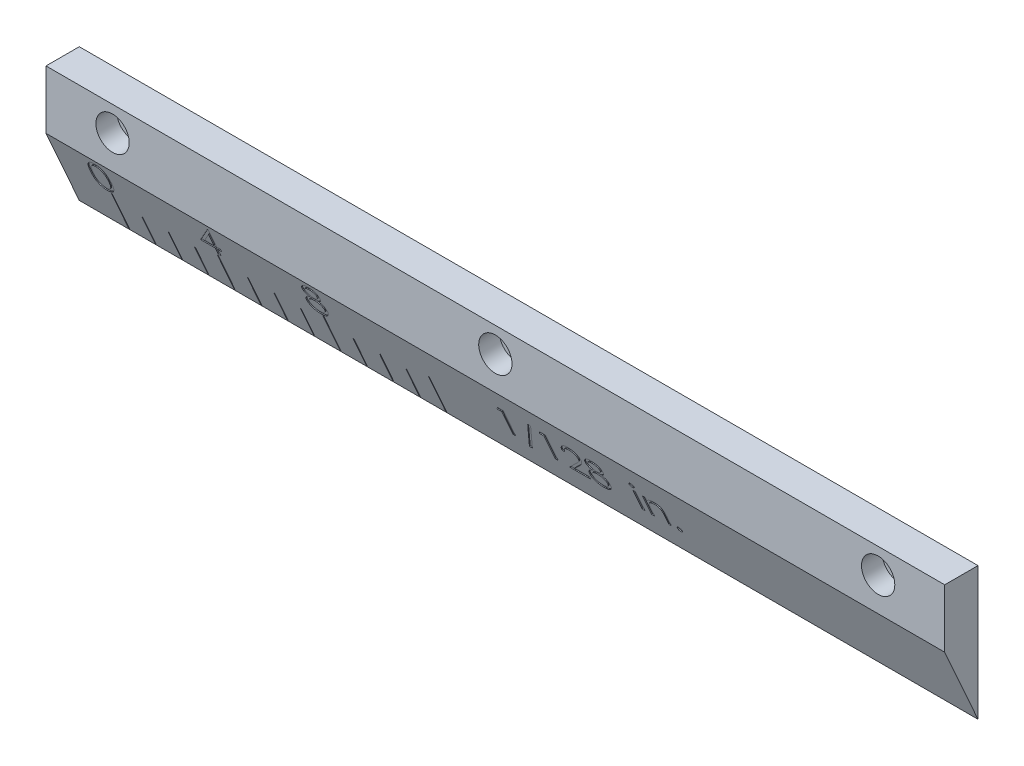
from build123d import *

# Parameters (mm, degrees)
SKETCH1_W           = 54
SKETCH1_H           = 8
BOSS_EXTRUDE1_DEPTH = 1
CUT_EXTRUDE1_DEPTH  = 55
SKETCH3_R           = 1
CUT_EXTRUDE2_DEPTH  = 1.25
SKETCH4_R           = 0.5
CUT_EXTRUDE3_DEPTH  = 1.75
SKETCH5_W           = 0.05
SKETCH5_H           = 2.58
SKETCH5_H_2         = 2
CUT_EXTRUDE4_DEPTH  = 0.05
CUT_EXTRUDE5_DEPTH  = 0.05
SKETCH7_W           = 0.166212607
SKETCH7_H           = 1.353445513
CUT_EXTRUDE6_DEPTH  = 0.05


with BuildPart() as part:
    # Sketch1 → Boss-Extrude1 (new body, symmetric)
    with BuildSketch(Plane.XY):
        Rectangle(SKETCH1_W, SKETCH1_H)
    extrude(amount=BOSS_EXTRUDE1_DEPTH, both=True)

    # Sketch2 → Cut-Extrude1 (cut, through all)
    with BuildSketch(Plane(origin=(27, 0, 0), x_dir=(0, 0, -1), z_dir=(1, 0, 0))):
        Polygon((-1, 0.492073548), (1, -4), (-1, -4), align=None)
    extrude(amount=-CUT_EXTRUDE1_DEPTH, mode=Mode.SUBTRACT)

    # Sketch3 → Cut-Extrude2 (cut)
    with BuildSketch(Plane.XY.offset(1)):
        with Locations((23, 2.5)):
            Circle(SKETCH3_R)
        with Locations((0, 2.5)):
            Circle(SKETCH3_R)
        with Locations((-23, 2.5)):
            Circle(SKETCH3_R)
    extrude(amount=-CUT_EXTRUDE2_DEPTH, mode=Mode.SUBTRACT)

    # Sketch4 → Cut-Extrude3 (cut, through all)
    with BuildSketch(Plane.XY.offset(-0.25)):
        with Locations((-23, 2.5)):
            Circle(SKETCH4_R)
        with Locations((0, 2.5)):
            Circle(SKETCH4_R)
        with Locations((23, 2.5)):
            Circle(SKETCH4_R)
    extrude(amount=-CUT_EXTRUDE3_DEPTH, mode=Mode.SUBTRACT)

    # Sketch5 → Cut-Extrude4 (cut)
    with BuildSketch(Plane(origin=(0, -0.290166375, 0.651724348), x_dir=(1, 0, 0), z_dir=(0, -0.406736643, 0.913545458))):
        with Locations((-23.975, -2.720918474)):
            Rectangle(SKETCH5_W, SKETCH5_H)
        with Locations((-22.3875, -3.010918474)):
            Rectangle(SKETCH5_W, SKETCH5_H_2)
        with Locations((-20.8, -3.010918474)):
            Rectangle(SKETCH5_W, SKETCH5_H_2)
        with Locations((-19.2125, -3.010918474)):
            Rectangle(SKETCH5_W, SKETCH5_H_2)
        with Locations((-17.625, -2.720918474)):
            Rectangle(SKETCH5_W, SKETCH5_H)
        with Locations((-16.0375, -3.010918474)):
            Rectangle(SKETCH5_W, SKETCH5_H_2)
        with Locations((-14.45, -3.010918474)):
            Rectangle(SKETCH5_W, SKETCH5_H_2)
        with Locations((-12.8625, -3.010918474)):
            Rectangle(SKETCH5_W, SKETCH5_H_2)
        with Locations((-11.275, -2.720918474)):
            Rectangle(SKETCH5_W, SKETCH5_H)
        with Locations((-9.6875, -3.010918474)):
            Rectangle(SKETCH5_W, SKETCH5_H_2)
        with Locations((-8.1, -3.010918474)):
            Rectangle(SKETCH5_W, SKETCH5_H_2)
        with Locations((-6.5125, -3.010918474)):
            Rectangle(SKETCH5_W, SKETCH5_H_2)
        with Locations((-4.925, -2.720918474)):
            Rectangle(SKETCH5_W, SKETCH5_H)
    extrude(amount=-CUT_EXTRUDE4_DEPTH, mode=Mode.SUBTRACT)

    # Sketch6 → Cut-Extrude5 (cut)
    with BuildSketch(Plane(origin=(0, -0.290166375, 0.651724348), x_dir=(1, 0, 0), z_dir=(0, -0.406736643, 0.913545458))):
        with BuildLine():
            add(Edge.make_bspline(
                [(-24.826395444, -0.386042742), (-24.826221867, -0.356357875), (-24.825884693, -0.298694591), (-24.822133737, -0.214671052), (-24.815902618, -0.135846232), (-24.807363258, -0.06221636), (-24.796971494, 0.006237574), (-24.783099132, 0.069332633), (-24.767323191, 0.127360842), (-24.749039188, 0.180511426), (-24.72840815, 0.22950046), (-24.705953354, 0.275233796), (-24.68078365, 0.317642235), (-24.654337534, 0.357402649), (-24.625544479, 0.393864188), (-24.595223869, 0.427541763), (-24.562192293, 0.457657035), (-24.527572618, 0.48509237), (-24.491051405, 0.509142716), (-24.453669661, 0.530326707), (-24.415170084, 0.548424136), (-24.375447562, 0.562653659), (-24.334859125, 0.574406898), (-24.293262886, 0.582444383), (-24.250590164, 0.587501581), (-24.221786863, 0.587985063), (-24.207179281, 0.588230261)],
                knots=[0, 0, 0, 0, 8.9049e-05, 0.00017298, 0.000252256, 0.00032621, 0.000395319, 0.000459867, 0.000519903, 0.000575635, 0.000628347, 0.000679285, 0.000728344, 0.000776193, 0.000822433, 0.000867605, 0.000911979, 0.000956364, 0.000999993, 0.001043021, 0.001085181, 0.001127434, 0.001169477, 0.001211825, 0.001254394, 0.001298198, 0.001298198, 0.001298198, 0.001298198], degree=3))
            add(Edge.make_bspline(
                [(-24.207179281, 0.588230261), (-24.192449674, 0.587972125), (-24.163157119, 0.587458775), (-24.119849921, 0.582524856), (-24.077543214, 0.574338053), (-24.036417366, 0.562738204), (-23.99613456, 0.548347158), (-23.957009878, 0.530309392), (-23.918800297, 0.509312658), (-23.88211302, 0.484640856), (-23.846545286, 0.457133569), (-23.812970739, 0.426038323), (-23.781386323, 0.391669097), (-23.75139564, 0.35439361), (-23.723849553, 0.31349692), (-23.697616945, 0.269690328), (-23.674136743, 0.222207745), (-23.651522978, 0.171841415), (-23.632003614, 0.117197728), (-23.614400226, 0.058584709), (-23.600176771, -0.004689965), (-23.588329115, -0.072294311), (-23.579150774, -0.144476604), (-23.572466001, -0.221082113), (-23.568934827, -0.302161236), (-23.568269822, -0.357595598), (-23.567928563, -0.386042742)],
                knots=[0, 0, 0, 0, 4.4175e-05, 8.785e-05, 0.000130562, 0.00017332, 0.000215921, 0.000258755, 0.00030243, 0.000346574, 0.000391251, 0.000437198, 0.00048367, 0.000531182, 0.000580577, 0.000631479, 0.000684243, 0.000739392, 0.000797018, 0.000858177, 0.000922887, 0.000991446, 0.001064018, 0.001141106, 0.001222072, 0.001307417, 0.001307417, 0.001307417, 0.001307417], degree=3))
            add(Edge.make_bspline(
                [(-23.567928563, -0.386042742), (-23.56827336, -0.41436581), (-23.568945183, -0.469552153), (-23.572426415, -0.550266461), (-23.579283691, -0.626465426), (-23.587861476, -0.698331795), (-23.599741777, -0.765566452), (-23.614349511, -0.828402056), (-23.63056864, -0.887109961), (-23.650589552, -0.941209215), (-23.67250272, -0.991454502), (-23.696344428, -1.038374201), (-23.721887211, -1.082383031), (-23.749715422, -1.12312873), (-23.779377019, -1.160899936), (-23.811506849, -1.195029928), (-23.845199201, -1.226341076), (-23.880871604, -1.254202562), (-23.91813105, -1.278589104), (-23.956209395, -1.3003981), (-23.995782268, -1.317983735), (-24.035952873, -1.333083527), (-24.0772958, -1.3446196), (-24.119759515, -1.352596181), (-24.163128023, -1.358190451), (-24.192444684, -1.358617213), (-24.207179281, -1.358831705)],
                knots=[0, 0, 0, 0, 8.4974e-05, 0.000165569, 0.000242288, 0.000314445, 0.000382639, 0.000446988, 0.000507939, 0.000565216, 0.000619877, 0.000672309, 0.000723023, 0.000772418, 0.000820221, 0.000866944, 0.000912891, 0.000958089, 0.001002542, 0.001046399, 0.00108957, 0.001132299, 0.001175057, 0.001218132, 0.00126185, 0.001306025, 0.001306025, 0.001306025, 0.001306025], degree=3))
            add(Edge.make_bspline(
                [(-24.207179281, -1.358831705), (-24.221786458, -1.358584925), (-24.25058896, -1.358098324), (-24.293267535, -1.353063974), (-24.334691995, -1.344970103), (-24.375066752, -1.33363715), (-24.41459895, -1.319765133), (-24.452749901, -1.301692142), (-24.489943801, -1.280877864), (-24.526081416, -1.25717362), (-24.560483684, -1.230015896), (-24.593344196, -1.199978127), (-24.623837436, -1.166310738), (-24.652218811, -1.129545337), (-24.679192599, -1.090020163), (-24.704004893, -1.047195566), (-24.726955303, -1.001241351), (-24.747933317, -0.951860623), (-24.766532818, -0.898332807), (-24.78296223, -0.840045534), (-24.795934305, -0.776484343), (-24.807037786, -0.708159736), (-24.815993605, -0.634778115), (-24.822107769, -0.55629964), (-24.825886715, -0.472773217), (-24.826222773, -0.415480462), (-24.826395444, -0.386042742)],
                knots=[0, 0, 0, 0, 4.3804e-05, 8.6374e-05, 0.000128721, 0.000170307, 0.000212085, 0.000254245, 0.000296767, 0.000339883, 0.000383747, 0.000428121, 0.000473293, 0.000519825, 0.000567366, 0.000616745, 0.000668181, 0.000721379, 0.000777583, 0.000838076, 0.000902909, 0.000972077, 0.001045706, 0.001124613, 0.001208173, 0.00129648, 0.00129648, 0.00129648, 0.00129648], degree=3))
        make_face()
        with BuildLine():
            add(Edge.make_bspline(
                [(-24.660182837, -0.385300722), (-24.660119629, -0.410038575), (-24.659996956, -0.45804989), (-24.656792217, -0.527816949), (-24.652426469, -0.592888748), (-24.646795449, -0.653347911), (-24.638433056, -0.708989793), (-24.629063214, -0.760197084), (-24.617660683, -0.806698788), (-24.604169569, -0.848814005), (-24.588803047, -0.88725747), (-24.572025361, -0.92302978), (-24.554001562, -0.956553513), (-24.533830178, -0.987527547), (-24.51186179, -1.016052892), (-24.488592607, -1.042634433), (-24.463154198, -1.066339502), (-24.427962635, -1.094769963), (-24.381503667, -1.124148838), (-24.322967009, -1.149731977), (-24.262817454, -1.16580936), (-24.221991584, -1.167853931), (-24.201614127, -1.16887444)],
                knots=[0, 0, 0, 0, 7.4206e-05, 0.000144019, 0.000209468, 0.000269864, 0.000326111, 0.000378211, 0.000425993, 0.00046964, 0.00051077, 0.000550106, 0.000588125, 0.000624862, 0.000660852, 0.000696069, 0.000730714, 0.000765016, 0.000831715, 0.000894853, 0.000956132, 0.001017199, 0.001017199, 0.001017199, 0.001017199], degree=3))
            add(Edge.make_bspline(
                [(-24.201614127, -1.16887444), (-24.181104859, -1.168028948), (-24.140128667, -1.166339708), (-24.080262034, -1.150042043), (-24.022143516, -1.125451912), (-23.976597114, -1.096375524), (-23.941945935, -1.068685116), (-23.917119028, -1.045076531), (-23.894332027, -1.018641551), (-23.872719762, -0.990119841), (-23.852897668, -0.958966485), (-23.834872591, -0.925331288), (-23.81842432, -0.889120848), (-23.809053283, -0.863842695), (-23.804262114, -0.850918627)],
                knots=[0, 0, 0, 0, 6.1406e-05, 0.000122686, 0.000184848, 0.00025021, 0.00028399, 0.000317842, 0.000352813, 0.000388579, 0.000425115, 0.00046346, 0.000502978, 0.000544318, 0.000544318, 0.000544318, 0.000544318], degree=3))
            add(Edge.make_bspline(
                [(-23.804262114, -0.850918627), (-23.79867847, -0.83439289), (-23.787341278, -0.800838557), (-23.772730048, -0.748787791), (-23.761223107, -0.694176328), (-23.750870826, -0.637330537), (-23.743804834, -0.577831195), (-23.73811745, -0.5158624), (-23.734767461, -0.45137743), (-23.734352197, -0.40756508), (-23.73414117, -0.385300722)],
                knots=[0, 0, 0, 0, 5.2327e-05, 0.000106246, 0.000162062, 0.000219704, 0.000279527, 0.000341735, 0.000406377, 0.000473169, 0.000473169, 0.000473169, 0.000473169], degree=3))
            add(Edge.make_bspline(
                [(-23.73414117, -0.385300722), (-23.734432312, -0.363039965), (-23.735001848, -0.319493165), (-23.737178833, -0.255718961), (-23.742800474, -0.195146438), (-23.749044175, -0.137514646), (-23.758250204, -0.083142611), (-23.76817621, -0.031575158), (-23.781511852, 0.01654886), (-23.795756899, 0.061982888), (-23.812060734, 0.104210735), (-23.83000781, 0.14342928), (-23.849175157, 0.179827864), (-23.869993759, 0.21330662), (-23.892216475, 0.244015507), (-23.916429845, 0.271338814), (-23.941673409, 0.296123376), (-23.977030836, 0.324413986), (-24.023319315, 0.353259758), (-24.080916803, 0.379805806), (-24.140855852, 0.395050194), (-24.181375972, 0.397199503), (-24.201614127, 0.398272996)],
                knots=[0, 0, 0, 0, 6.6791e-05, 0.000130658, 0.000191355, 0.000249248, 0.000304509, 0.000356751, 0.0004067, 0.00045422, 0.000499556, 0.00054239, 0.00058355, 0.000622877, 0.000660574, 0.000697117, 0.000732275, 0.000766577, 0.000832764, 0.000895373, 0.000956201, 0.001016899, 0.001016899, 0.001016899, 0.001016899], degree=3))
            add(Edge.make_bspline(
                [(-24.201614127, 0.398272996), (-24.222098482, 0.397198022), (-24.263104509, 0.395046116), (-24.323666552, 0.379862603), (-24.381718438, 0.353397408), (-24.427884512, 0.324318445), (-24.463266599, 0.296622755), (-24.488181191, 0.272605756), (-24.511541874, 0.246334613), (-24.533061865, 0.217546933), (-24.553217444, 0.18660901), (-24.57172823, 0.153277455), (-24.588406151, 0.117383358), (-24.603796718, 0.078957161), (-24.617328985, 0.036845578), (-24.628491207, -0.009598848), (-24.638803106, -0.060643266), (-24.646103102, -0.116586505), (-24.652592673, -0.177060811), (-24.65676322, -0.242295059), (-24.660007677, -0.312179127), (-24.660123281, -0.360438682), (-24.660182837, -0.385300722)],
                knots=[0, 0, 0, 0, 6.1437e-05, 0.000122985, 0.000185932, 0.00025212, 0.000286191, 0.000320567, 0.000355783, 0.000391549, 0.000428286, 0.000466484, 0.00050582, 0.00054695, 0.000590597, 0.000638378, 0.000690184, 0.000746746, 0.000807549, 0.000872628, 0.000942812, 0.001017389, 0.001017389, 0.001017389, 0.001017389], degree=3))
        make_face(mode=Mode.SUBTRACT)
        Polygon((-17.40433473, 0.588230261), (-17.370572794, 0.588230261), (-17.370572794, -0.693981277), (-17.156870871, -0.693981277), (-17.156870871, -0.883938542), (-17.370572794, -0.883938542), (-17.370572794, -1.311342389), (-17.536785401, -1.311342389), (-17.536785401, -0.883938542), (-18.415337751, -0.883938542), align=None)
        Polygon((-17.536785401, -0.693981277), (-17.536785401, 0.110369016), (-18.088848702, -0.693981277), align=None, mode=Mode.SUBTRACT)
        with BuildLine():
            add(Edge.make_bspline(
                [(-11.103838102, -0.279562791), (-11.088678246, -0.28746746), (-11.059111463, -0.302884203), (-11.017001857, -0.327707849), (-10.978518211, -0.35387036), (-10.942592788, -0.380136002), (-10.909856765, -0.407510667), (-10.88067618, -0.436103213), (-10.854330231, -0.465199942), (-10.831350225, -0.495293566), (-10.811137732, -0.526304134), (-10.79366881, -0.558313041), (-10.778737207, -0.591250139), (-10.766903486, -0.625474961), (-10.757155287, -0.660484766), (-10.75044778, -0.696731615), (-10.746840494, -0.733976662), (-10.746158497, -0.759148222), (-10.745813179, -0.771893437)],
                knots=[0, 0, 0, 0, 5.1287e-05, 0.000100026, 0.000146537, 0.000190837, 0.000233495, 0.000274424, 0.000313308, 0.000351153, 0.00038789, 0.000424251, 0.000460453, 0.000496241, 0.000532783, 0.000569386, 0.000606672, 0.000644915, 0.000644915, 0.000644915, 0.000644915], degree=3))
            add(Edge.make_bspline(
                [(-10.745813179, -0.771893437), (-10.746221389, -0.789725154), (-10.74702939, -0.825020812), (-10.754067298, -0.877115213), (-10.764604582, -0.927709781), (-10.779992491, -0.976793424), (-10.79994916, -1.024095301), (-10.824543153, -1.069655901), (-10.852383249, -1.114221953), (-10.874741725, -1.141643053), (-10.886055066, -1.15551807)],
                knots=[0, 0, 0, 0, 5.3472e-05, 0.000105841, 0.000157433, 0.00020836, 0.000259902, 0.000311189, 0.000363575, 0.000417233, 0.000417233, 0.000417233, 0.000417233], degree=3))
            add(Edge.make_bspline(
                [(-10.886055066, -1.15551807), (-10.9007852, -1.171707275), (-10.930063444, -1.203885632), (-10.98021941, -1.245663769), (-11.035264324, -1.280773656), (-11.094985191, -1.309386701), (-11.159222374, -1.331657134), (-11.227962185, -1.347660467), (-11.301338633, -1.356826919), (-11.351771111, -1.358151947), (-11.377643691, -1.358831705)],
                knots=[0, 0, 0, 0, 6.5605e-05, 0.000130399, 0.000195135, 0.000261013, 0.000328598, 0.000398703, 0.000472378, 0.000549991, 0.000549991, 0.000549991, 0.000549991], degree=3))
            add(Edge.make_bspline(
                [(-11.377643691, -1.358831705), (-11.402521609, -1.358221852), (-11.450931511, -1.35703514), (-11.521394221, -1.348994753), (-11.587076012, -1.334904174), (-11.648358787, -1.315618901), (-11.704873096, -1.290530989), (-11.756457903, -1.259305706), (-11.803857464, -1.223199901), (-11.845633306, -1.181176618), (-11.882721774, -1.136166827), (-11.915301535, -1.089731601), (-11.942381152, -1.041866699), (-11.965308407, -0.99328583), (-11.982859819, -0.943308073), (-11.995015947, -0.892190566), (-12.002736125, -0.840022595), (-12.003763309, -0.804816261), (-12.004280059, -0.787104859)],
                knots=[0, 0, 0, 0, 7.4632e-05, 0.000145227, 0.000212392, 0.000275869, 0.000337649, 0.000397395, 0.000456391, 0.000515943, 0.000574705, 0.000631208, 0.000685878, 0.000739491, 0.000792176, 0.000844458, 0.000896927, 0.000950045, 0.000950045, 0.000950045, 0.000950045], degree=3))
            add(Edge.make_bspline(
                [(-12.004280059, -0.787104859), (-12.003974264, -0.774108953), (-12.003369904, -0.748424456), (-11.999186922, -0.71047827), (-11.992462028, -0.673544482), (-11.983328899, -0.637486671), (-11.970951147, -0.602567348), (-11.956006352, -0.568621056), (-11.93857986, -0.53560947), (-11.918428577, -0.503352062), (-11.894985423, -0.47230082), (-11.868440491, -0.441928773), (-11.838263244, -0.412707202), (-11.8047894, -0.384279085), (-11.768401497, -0.356140132), (-11.728154388, -0.329811059), (-11.685115004, -0.303427886), (-11.65452631, -0.287654314), (-11.63883493, -0.279562791)],
                knots=[0, 0, 0, 0, 3.8984e-05, 7.7047e-05, 0.000114379, 0.000151543, 0.000188505, 0.000225384, 0.000262726, 0.000300401, 0.000339357, 0.00037932, 0.000421298, 0.000465242, 0.000511027, 0.000559184, 0.00060945, 0.000662395, 0.000662395, 0.000662395, 0.000662395], degree=3))
            add(Edge.make_bspline(
                [(-11.63883493, -0.279562791), (-11.660314533, -0.267849809), (-11.701905055, -0.245170198), (-11.756975134, -0.203500014), (-11.804277673, -0.158368545), (-11.842512461, -0.108822778), (-11.872607348, -0.056410474), (-11.893254693, -0.001459557), (-11.907222832, 0.055011053), (-11.908606512, 0.093590582), (-11.909301427, 0.112966088)],
                knots=[0, 0, 0, 0, 7.3308e-05, 0.000141945, 0.00020649, 0.000268902, 0.000329048, 0.000387063, 0.000444571, 0.000502592, 0.000502592, 0.000502592, 0.000502592], degree=3))
            add(Edge.make_bspline(
                [(-11.909301427, 0.112966088), (-11.908436015, 0.132702713), (-11.906696386, 0.17237677), (-11.892629379, 0.231435011), (-11.869705843, 0.289440443), (-11.838526816, 0.346111924), (-11.799692747, 0.399531413), (-11.75310145, 0.447442664), (-11.699865539, 0.489411657), (-11.640250751, 0.524641548), (-11.576096576, 0.553313734), (-11.508407839, 0.57309315), (-11.438363903, 0.586023928), (-11.390687193, 0.587487949), (-11.366513382, 0.588230261)],
                knots=[0, 0, 0, 0, 5.9158e-05, 0.000118919, 0.000181064, 0.000245821, 0.000312459, 0.000378578, 0.000445677, 0.000515222, 0.000585816, 0.000655894, 0.000726345, 0.000798807, 0.000798807, 0.000798807, 0.000798807], degree=3))
            add(Edge.make_bspline(
                [(-11.366513382, 0.588230261), (-11.342963447, 0.587464904), (-11.296525657, 0.585955708), (-11.228266, 0.573368486), (-11.162953669, 0.552344948), (-11.100813893, 0.523824334), (-11.042959113, 0.488694578), (-10.991840391, 0.446149115), (-10.946685233, 0.398449211), (-10.909334324, 0.345045921), (-10.878556462, 0.288592202), (-10.857124735, 0.229525285), (-10.843391815, 0.169121408), (-10.84165966, 0.128249631), (-10.840791811, 0.107771944)],
                knots=[0, 0, 0, 0, 7.061e-05, 0.000139235, 0.000207405, 0.00027597, 0.000343928, 0.000409816, 0.000474911, 0.000540381, 0.000604785, 0.000667229, 0.000728357, 0.000789735, 0.000789735, 0.000789735, 0.000789735], degree=3))
            add(Edge.make_bspline(
                [(-10.840791811, 0.107771944), (-10.841550933, 0.08767596), (-10.843041805, 0.048208588), (-10.855583023, -0.009325862), (-10.876703818, -0.063206691), (-10.905540312, -0.114045295), (-10.943124633, -0.160919671), (-10.988955087, -0.204425886), (-11.042666286, -0.244921333), (-11.083021005, -0.267774117), (-11.103838102, -0.279562791)],
                knots=[0, 0, 0, 0, 6.0242e-05, 0.000118312, 0.000175635, 0.000233296, 0.000292977, 0.000355166, 0.000422467, 0.000494176, 0.000494176, 0.000494176, 0.000494176], degree=3))
        make_face()
        with BuildLine():
            add(Edge.make_bspline(
                [(-11.375788639, 0.398272996), (-11.388780108, 0.397928275), (-11.4141971, 0.397253851), (-11.451465605, 0.393730322), (-11.486905149, 0.386875912), (-11.52088601, 0.37775376), (-11.552942299, 0.365430533), (-11.583509375, 0.350934008), (-11.612067013, 0.333309548), (-11.638959953, 0.313539247), (-11.663169738, 0.291794251), (-11.684656313, 0.269138658), (-11.702504107, 0.245127513), (-11.717660027, 0.22035809), (-11.728656913, 0.194095243), (-11.736893024, 0.167144162), (-11.742460594, 0.139164271), (-11.742877784, 0.120042035), (-11.74308882, 0.110369016)],
                knots=[0, 0, 0, 0, 3.8984e-05, 7.627e-05, 0.000112143, 0.000147156, 0.000181678, 0.000215032, 0.000248501, 0.00028219, 0.000315034, 0.000346008, 0.000375689, 0.00040464, 0.000432895, 0.000460827, 0.000489134, 0.00051811, 0.00051811, 0.00051811, 0.00051811], degree=3))
            add(Edge.make_bspline(
                [(-11.74308882, 0.110369016), (-11.742725088, 0.10069558), (-11.742006302, 0.08157948), (-11.736447338, 0.053350626), (-11.728162253, 0.025610843), (-11.715117944, -0.000980264), (-11.699472413, -0.027345125), (-11.68016234, -0.05282481), (-11.657149397, -0.077507993), (-11.631205709, -0.10118473), (-11.602942104, -0.123356159), (-11.572999714, -0.142603634), (-11.541754332, -0.158708351), (-11.509526987, -0.172111828), (-11.475989226, -0.182531086), (-11.44134655, -0.189922828), (-11.405593138, -0.194517052), (-11.381367581, -0.195065809), (-11.369110454, -0.195343457)],
                knots=[0, 0, 0, 0, 2.8998e-05, 5.7305e-05, 8.6055e-05, 0.000115596, 0.000145883, 0.000177938, 0.000211282, 0.000246995, 0.000283212, 0.000318924, 0.000353605, 0.000388537, 0.000423506, 0.000458799, 0.000494693, 0.000531453, 0.000531453, 0.000531453, 0.000531453], degree=3))
            add(Edge.make_bspline(
                [(-11.369110454, -0.195343457), (-11.353367691, -0.194881565), (-11.322037655, -0.193962342), (-11.275852342, -0.18541568), (-11.230945859, -0.171971715), (-11.187798189, -0.153577899), (-11.147526179, -0.13049149), (-11.111627477, -0.102851518), (-11.080408287, -0.0712962), (-11.054193048, -0.036316783), (-11.033867837, 0.000910933), (-11.018044797, 0.038270254), (-11.008804904, 0.076159768), (-11.007599692, 0.101542287), (-11.007004418, 0.114079119)],
                knots=[0, 0, 0, 0, 4.719e-05, 9.3914e-05, 0.000140395, 0.000187601, 0.00023431, 0.00027928, 0.000323093, 0.000367094, 0.000409941, 0.000450039, 0.000488555, 0.000526144, 0.000526144, 0.000526144, 0.000526144], degree=3))
            add(Edge.make_bspline(
                [(-11.007004418, 0.114079119), (-11.007285881, 0.122878122), (-11.007844543, 0.14034288), (-11.012448323, 0.166133598), (-11.020055534, 0.191337586), (-11.030354748, 0.216163054), (-11.043906597, 0.240261692), (-11.059974313, 0.264012326), (-11.079492362, 0.286880668), (-11.101397975, 0.309399645), (-11.12623992, 0.330240358), (-11.153970324, 0.348567892), (-11.184447016, 0.364131931), (-11.217670719, 0.376773063), (-11.253519075, 0.386267557), (-11.291826971, 0.393377624), (-11.332913824, 0.397385062), (-11.361187067, 0.397970599), (-11.375788639, 0.398272996)],
                knots=[0, 0, 0, 0, 2.6384e-05, 5.2367e-05, 7.8309e-05, 0.00010525, 0.000132817, 0.000161117, 0.000191139, 0.000222883, 0.00025528, 0.000288208, 0.00032239, 0.000357737, 0.000394637, 0.000433496, 0.000474511, 0.000518315, 0.000518315, 0.000518315, 0.000518315], degree=3))
        make_face(mode=Mode.SUBTRACT)
        with BuildLine():
            add(Edge.make_bspline(
                [(-11.365029341, -0.385300722), (-11.381500069, -0.38559369), (-11.413811619, -0.386168423), (-11.461149244, -0.392565784), (-11.506579877, -0.401471338), (-11.549950343, -0.414981406), (-11.591242328, -0.432547883), (-11.630679364, -0.45367991), (-11.667959754, -0.478659457), (-11.702568696, -0.507169166), (-11.734172292, -0.537892294), (-11.761899725, -0.570416007), (-11.78544633, -0.604135847), (-11.804408092, -0.639480069), (-11.8199718, -0.675700263), (-11.83019206, -0.713698448), (-11.836744049, -0.752744129), (-11.837623858, -0.779287181), (-11.838067452, -0.792670013)],
                knots=[0, 0, 0, 0, 4.9379e-05, 9.687e-05, 0.000143074, 0.000188136, 0.000232858, 0.00027751, 0.000322169, 0.000367251, 0.000411852, 0.000454227, 0.00049529, 0.000534968, 0.00057438, 0.000613266, 0.000652729, 0.00069286, 0.00069286, 0.00069286, 0.00069286], degree=3))
            add(Edge.make_bspline(
                [(-11.838067452, -0.792670013), (-11.837346061, -0.809302201), (-11.835914838, -0.842300073), (-11.8245607, -0.891069698), (-11.806338562, -0.938282506), (-11.780925219, -0.983553748), (-11.749456962, -1.025860679), (-11.710760873, -1.062737656), (-11.667241763, -1.095504438), (-11.617427148, -1.122005387), (-11.563013752, -1.143169332), (-11.504016045, -1.157751028), (-11.441280734, -1.167403796), (-11.397963366, -1.1683765), (-11.375788639, -1.16887444)],
                knots=[0, 0, 0, 0, 4.9854e-05, 9.8908e-05, 0.000149412, 0.000201232, 0.000254212, 0.000306949, 0.000361043, 0.000417154, 0.000475649, 0.000535758, 0.000599141, 0.000665618, 0.000665618, 0.000665618, 0.000665618], degree=3))
            add(Edge.make_bspline(
                [(-11.375788639, -1.16887444), (-11.358458236, -1.168541695), (-11.324693054, -1.167893403), (-11.275435073, -1.162170838), (-11.228950666, -1.153095829), (-11.185329976, -1.139896536), (-11.144084695, -1.123783423), (-11.105914128, -1.103054863), (-11.069836324, -1.079479259), (-11.037629059, -1.051508485), (-11.008295653, -1.021621419), (-10.982719286, -0.989982521), (-10.960516748, -0.957451665), (-10.943090784, -0.923293701), (-10.929159808, -0.888163958), (-10.919146094, -0.8517385), (-10.91296743, -0.813905606), (-10.912342539, -0.788241514), (-10.912025786, -0.775232529)],
                knots=[0, 0, 0, 0, 5.1975e-05, 0.000101263, 0.000148558, 0.000193867, 0.000237822, 0.000281143, 0.000323949, 0.000366847, 0.000408825, 0.000449443, 0.000488751, 0.00052675, 0.00056423, 0.000601943, 0.000639883, 0.000678883, 0.000678883, 0.000678883, 0.000678883], degree=3))
            add(Edge.make_bspline(
                [(-10.912025786, -0.775232529), (-10.91250513, -0.762597437), (-10.913450315, -0.737683241), (-10.919449314, -0.700765121), (-10.929988132, -0.665097798), (-10.94444888, -0.63025217), (-10.963700472, -0.596934275), (-10.98637255, -0.564276135), (-11.013727354, -0.533184183), (-11.044637353, -0.503416919), (-11.078323553, -0.475891925), (-11.11413075, -0.451542618), (-11.15178332, -0.43103629), (-11.191201586, -0.414358811), (-11.232298021, -0.401242109), (-11.2750424, -0.392079061), (-11.319484767, -0.386311355), (-11.349676302, -0.385641405), (-11.365029341, -0.385300722)],
                knots=[0, 0, 0, 0, 3.7908e-05, 7.4749e-05, 0.00011185, 0.000149265, 0.000187644, 0.000227066, 0.000268355, 0.000311649, 0.000355687, 0.0003987, 0.000441368, 0.000484092, 0.000526919, 0.000570582, 0.000615081, 0.000661124, 0.000661124, 0.000661124, 0.000661124], degree=3))
        make_face(mode=Mode.SUBTRACT)
    extrude(amount=-CUT_EXTRUDE5_DEPTH, mode=Mode.SUBTRACT)

    # Sketch7 → Cut-Extrude6 (cut)
    with BuildSketch(Plane(origin=(0, -0.290166375, 0.651724348), x_dir=(1, 0, 0), z_dir=(0, -0.406736643, 0.913545458))):
        Polygon((-0.423520394, -0.510456047), (-0.081077903, -0.510456047), (-0.081077903, -2.362539381), (-0.247290509, -2.362539381), (-0.247290509, -0.700413312), (-0.532226407, -0.700413312), align=None)
        Polygon((1.581048166, -0.462966731), (0.806378695, -2.62373062), (0.631261841, -2.62373062), (1.405931312, -0.462966731), align=None)
        Polygon((2.117158025, -0.510456047), (2.459600516, -0.510456047), (2.459600516, -2.362539381), (2.293387909, -2.362539381), (2.293387909, -0.700413312), (2.008452012, -0.700413312), align=None)
        with BuildLine():
            Line((3.385642183, -1.080327842), (3.219429576, -1.080327842))
            add(Edge.make_bspline(
                [(3.219429576, -1.080327842), (3.220512861, -1.058276997), (3.222640404, -1.014969725), (3.232603707, -0.951827491), (3.246859922, -0.891473494), (3.267016649, -0.834392331), (3.292049555, -0.780079295), (3.322069194, -0.72875012), (3.35762594, -0.680600616), (3.397952004, -0.636077145), (3.441750408, -0.595232056), (3.489008135, -0.559960323), (3.538667795, -0.530158888), (3.590578727, -0.505245065), (3.645326608, -0.486544396), (3.702414621, -0.472668779), (3.76209358, -0.464320462), (3.802754759, -0.463423109), (3.823434317, -0.462966731)],
                knots=[0, 0, 0, 0, 6.619e-05, 0.000129995, 0.000191455, 0.000252001, 0.000311263, 0.000370631, 0.000430069, 0.00049049, 0.000550613, 0.000609455, 0.000667039, 0.000724127, 0.000781855, 0.000840256, 0.000900176, 0.000962189, 0.000962189, 0.000962189, 0.000962189], degree=3))
            add(Edge.make_bspline(
                [(3.823434317, -0.462966731), (3.843742715, -0.463442164), (3.88364799, -0.464376374), (3.94188914, -0.472399085), (3.997333791, -0.48496446), (4.049873568, -0.502593868), (4.099089277, -0.526292294), (4.145350638, -0.554760159), (4.1892084, -0.587684819), (4.228687823, -0.626448296), (4.264940015, -0.667830391), (4.296214959, -0.712009406), (4.322997758, -0.75763907), (4.345322072, -0.805067327), (4.361755945, -0.854740746), (4.374232747, -0.905936141), (4.38128517, -0.959183437), (4.38236754, -0.995223156), (4.382917824, -1.013545991)],
                knots=[0, 0, 0, 0, 6.0901e-05, 0.000119668, 0.000176008, 0.000231269, 0.000285534, 0.000339493, 0.000394033, 0.000449659, 0.000505154, 0.000558893, 0.00061177, 0.000663725, 0.000715817, 0.00076846, 0.000821613, 0.000876584, 0.000876584, 0.000876584, 0.000876584], degree=3))
            add(Edge.make_bspline(
                [(4.382917824, -1.013545991), (4.382021806, -1.03934172), (4.380245493, -1.0904805), (4.365050802, -1.165630032), (4.341319523, -1.238439883), (4.312745922, -1.297038372), (4.28392092, -1.344257762), (4.257945448, -1.383134952), (4.227536985, -1.424994929), (4.192252947, -1.46969752), (4.152823218, -1.517592874), (4.108890657, -1.568652057), (4.060141981, -1.622347535), (4.025926858, -1.659021749), (4.008197438, -1.678025408)],
                knots=[0, 0, 0, 0, 7.7321e-05, 0.000153285, 0.000229076, 0.000306567, 0.00034818, 0.000395, 0.000446799, 0.000503354, 0.000565821, 0.000632904, 0.000705404, 0.000783374, 0.000783374, 0.000783374, 0.000783374], degree=3))
            Line((4.008197438, -1.678025408), (3.544805594, -2.172582116))
            Line((3.544805594, -2.172582116), (4.406662482, -2.172582116))
            Line((4.406662482, -2.172582116), (4.406662482, -2.362539381))
            Line((4.406662482, -2.362539381), (3.148195602, -2.362539381))
            Line((3.148195602, -2.362539381), (3.86647151, -1.596032136))
            add(Edge.make_bspline(
                [(3.86647151, -1.596032136), (3.88395935, -1.577776782), (3.917549912, -1.542711983), (3.965059859, -1.491518833), (4.007731323, -1.444026368), (4.045840527, -1.400324319), (4.078560757, -1.359773448), (4.107597313, -1.323687084), (4.130862438, -1.290479521), (4.156111835, -1.251987613), (4.180566734, -1.204991095), (4.201581189, -1.147558684), (4.214394879, -1.088436346), (4.215932021, -1.048483185), (4.216705217, -1.028386403)],
                knots=[0, 0, 0, 0, 7.584e-05, 0.000145672, 0.000209513, 0.000267381, 0.00031959, 0.000365829, 0.000406285, 0.000441171, 0.000503897, 0.000564693, 0.000624215, 0.000684457, 0.000684457, 0.000684457, 0.000684457], degree=3))
            add(Edge.make_bspline(
                [(4.216705217, -1.028386403), (4.216368803, -1.015749163), (4.215705797, -0.990843589), (4.209854432, -0.954328042), (4.201011789, -0.919104161), (4.188340757, -0.8850636), (4.171615523, -0.852548609), (4.151256693, -0.821519609), (4.127766951, -0.791521699), (4.100593571, -0.763394745), (4.070742475, -0.737634274), (4.039207185, -0.714814445), (4.005843171, -0.695743749), (3.970791107, -0.680110315), (3.934148713, -0.667846676), (3.895845118, -0.659349011), (3.85598616, -0.654013697), (3.828769268, -0.653291822), (3.81490108, -0.652923996)],
                knots=[0, 0, 0, 0, 3.7888e-05, 7.4671e-05, 0.000110665, 0.000146706, 0.000183376, 0.000220114, 0.000257893, 0.000297515, 0.000337234, 0.00037605, 0.000414107, 0.000452305, 0.000491022, 0.000529815, 0.000569851, 0.000611446, 0.000611446, 0.000611446, 0.000611446], degree=3))
            add(Edge.make_bspline(
                [(3.81490108, -0.652923996), (3.800417348, -0.653302367), (3.771973689, -0.654045426), (3.730212368, -0.659243252), (3.690373644, -0.668210426), (3.652357303, -0.68047475), (3.616099023, -0.696063232), (3.581775133, -0.71547928), (3.549462687, -0.738648045), (3.519100944, -0.764916173), (3.491127088, -0.794161945), (3.466548949, -0.826763884), (3.445073242, -0.862126725), (3.426335856, -0.900155049), (3.411119303, -0.941193924), (3.399491844, -0.985097668), (3.390291305, -1.031675649), (3.387217629, -1.06384109), (3.385642183, -1.080327842)],
                knots=[0, 0, 0, 0, 4.3448e-05, 8.5324e-05, 0.000126009, 0.000165783, 0.000205, 0.000244208, 0.000283843, 0.000324086, 0.0003645, 0.000405015, 0.000446311, 0.000488456, 0.00053201, 0.00057737, 0.000624594, 0.000674251, 0.000674251, 0.000674251, 0.000674251], degree=3))
        make_face()
        with BuildLine():
            add(Edge.make_bspline(
                [(5.473317046, -1.330759783), (5.488476902, -1.338664452), (5.518043685, -1.354081195), (5.560153291, -1.378904841), (5.598636937, -1.405067352), (5.634562359, -1.431332994), (5.667298383, -1.45870766), (5.696478968, -1.487300205), (5.722824917, -1.516396934), (5.745804923, -1.546490558), (5.766017416, -1.577501126), (5.783486337, -1.609510033), (5.798417941, -1.642447131), (5.810251662, -1.676671953), (5.81999986, -1.711681758), (5.826707368, -1.747928607), (5.830314654, -1.785173654), (5.830996651, -1.810345214), (5.831341969, -1.823090429)],
                knots=[0, 0, 0, 0, 5.1287e-05, 0.000100026, 0.000146537, 0.000190837, 0.000233495, 0.000274424, 0.000313308, 0.000351153, 0.00038789, 0.000424251, 0.000460453, 0.000496241, 0.000532783, 0.000569386, 0.000606672, 0.000644915, 0.000644915, 0.000644915, 0.000644915], degree=3))
            add(Edge.make_bspline(
                [(5.831341969, -1.823090429), (5.830933759, -1.840922146), (5.830125758, -1.876217804), (5.82308785, -1.928312205), (5.812550566, -1.978906773), (5.797162657, -2.027990416), (5.777205988, -2.075292293), (5.752611995, -2.120852894), (5.724771899, -2.165418945), (5.702413423, -2.192840045), (5.691100082, -2.206715062)],
                knots=[0, 0, 0, 0, 5.3472e-05, 0.000105841, 0.000157433, 0.00020836, 0.000259902, 0.000311189, 0.000363575, 0.000417233, 0.000417233, 0.000417233, 0.000417233], degree=3))
            add(Edge.make_bspline(
                [(5.691100082, -2.206715062), (5.676369948, -2.222904267), (5.647091704, -2.255082624), (5.596935738, -2.296860761), (5.541890824, -2.331970648), (5.482169957, -2.360583693), (5.417932774, -2.382854126), (5.349192963, -2.398857459), (5.275816515, -2.408023911), (5.225384037, -2.409348939), (5.199511457, -2.410028697)],
                knots=[0, 0, 0, 0, 6.5605e-05, 0.000130399, 0.000195135, 0.000261013, 0.000328598, 0.000398703, 0.000472378, 0.000549991, 0.000549991, 0.000549991, 0.000549991], degree=3))
            add(Edge.make_bspline(
                [(5.199511457, -2.410028697), (5.174633539, -2.409418844), (5.126223637, -2.408232132), (5.055760927, -2.400191745), (4.990079136, -2.386101166), (4.928796361, -2.366815894), (4.872282052, -2.341727981), (4.820697245, -2.310502698), (4.773297684, -2.274396893), (4.731521842, -2.23237361), (4.694433374, -2.187363819), (4.661853612, -2.140928593), (4.634773996, -2.093063691), (4.611846741, -2.044482822), (4.594295329, -1.994505065), (4.582139201, -1.943387558), (4.574419023, -1.891219587), (4.573391839, -1.856013254), (4.572875089, -1.838301851)],
                knots=[0, 0, 0, 0, 7.4632e-05, 0.000145227, 0.000212392, 0.000275869, 0.000337649, 0.000397395, 0.000456391, 0.000515943, 0.000574705, 0.000631208, 0.000685878, 0.000739491, 0.000792176, 0.000844458, 0.000896927, 0.000950045, 0.000950045, 0.000950045, 0.000950045], degree=3))
            add(Edge.make_bspline(
                [(4.572875089, -1.838301851), (4.573180884, -1.825305945), (4.573785244, -1.799621448), (4.577968226, -1.761675262), (4.58469312, -1.724741474), (4.593826249, -1.688683664), (4.606204001, -1.65376434), (4.621148796, -1.619818048), (4.638575288, -1.586806462), (4.658726571, -1.554549054), (4.682169725, -1.523497812), (4.708714657, -1.493125765), (4.738891904, -1.463904194), (4.772365748, -1.435476077), (4.808753651, -1.407337125), (4.84900076, -1.381008051), (4.892040144, -1.354624878), (4.922628838, -1.338851306), (4.938320218, -1.330759783)],
                knots=[0, 0, 0, 0, 3.8984e-05, 7.7047e-05, 0.000114379, 0.000151543, 0.000188505, 0.000225384, 0.000262726, 0.000300401, 0.000339357, 0.00037932, 0.000421298, 0.000465242, 0.000511027, 0.000559184, 0.00060945, 0.000662395, 0.000662395, 0.000662395, 0.000662395], degree=3))
            add(Edge.make_bspline(
                [(4.938320218, -1.330759783), (4.916840615, -1.319046802), (4.875250093, -1.29636719), (4.820180014, -1.254697006), (4.772877475, -1.209565537), (4.734642687, -1.16001977), (4.7045478, -1.107607466), (4.683900455, -1.052656549), (4.669932316, -0.996185939), (4.668548636, -0.95760641), (4.667853721, -0.938230904)],
                knots=[0, 0, 0, 0, 7.3308e-05, 0.000141945, 0.00020649, 0.000268902, 0.000329048, 0.000387063, 0.000444571, 0.000502592, 0.000502592, 0.000502592, 0.000502592], degree=3))
            add(Edge.make_bspline(
                [(4.667853721, -0.938230904), (4.668719133, -0.918494279), (4.670458762, -0.878820222), (4.684525769, -0.819761981), (4.707449305, -0.761756549), (4.738628332, -0.705085068), (4.777462401, -0.651665579), (4.824053698, -0.603754328), (4.877289609, -0.561785335), (4.936904397, -0.526555444), (5.001058572, -0.497883258), (5.068747309, -0.478103843), (5.138791245, -0.465173064), (5.186467955, -0.463709043), (5.210641766, -0.462966731)],
                knots=[0, 0, 0, 0, 5.9158e-05, 0.000118919, 0.000181064, 0.000245821, 0.000312459, 0.000378578, 0.000445677, 0.000515222, 0.000585816, 0.000655894, 0.000726345, 0.000798807, 0.000798807, 0.000798807, 0.000798807], degree=3))
            add(Edge.make_bspline(
                [(5.210641766, -0.462966731), (5.234191701, -0.463732088), (5.280629491, -0.465241284), (5.348889148, -0.477828507), (5.414201479, -0.498852044), (5.476341255, -0.527372658), (5.534196035, -0.562502414), (5.585314757, -0.605047877), (5.630469915, -0.652747781), (5.667820824, -0.706151071), (5.698598686, -0.76260479), (5.720030413, -0.821671707), (5.733763333, -0.882075584), (5.735495488, -0.922947361), (5.736363337, -0.943425048)],
                knots=[0, 0, 0, 0, 7.061e-05, 0.000139235, 0.000207405, 0.00027597, 0.000343928, 0.000409816, 0.000474911, 0.000540381, 0.000604785, 0.000667229, 0.000728357, 0.000789735, 0.000789735, 0.000789735, 0.000789735], degree=3))
            add(Edge.make_bspline(
                [(5.736363337, -0.943425048), (5.735604215, -0.963521032), (5.734113343, -1.002988404), (5.721572125, -1.060522854), (5.70045133, -1.114403683), (5.671614836, -1.165242287), (5.634030515, -1.212116663), (5.588200061, -1.255622878), (5.534488862, -1.296118325), (5.494134143, -1.318971109), (5.473317046, -1.330759783)],
                knots=[0, 0, 0, 0, 6.0242e-05, 0.000118312, 0.000175635, 0.000233296, 0.000292977, 0.000355166, 0.000422467, 0.000494176, 0.000494176, 0.000494176, 0.000494176], degree=3))
        make_face()
        with BuildLine():
            add(Edge.make_bspline(
                [(5.201366509, -0.652923996), (5.18837504, -0.653268717), (5.162958048, -0.653943141), (5.125689543, -0.65746667), (5.090249999, -0.66432108), (5.056269138, -0.673443232), (5.024212849, -0.685766459), (4.993645773, -0.700262985), (4.965088135, -0.717887444), (4.938195195, -0.737657745), (4.91398541, -0.759402741), (4.892498835, -0.782058334), (4.874651041, -0.806069479), (4.859495121, -0.830838902), (4.848498235, -0.857101749), (4.840262124, -0.88405283), (4.834694554, -0.912032721), (4.834277364, -0.931154957), (4.834066328, -0.940827976)],
                knots=[0, 0, 0, 0, 3.8984e-05, 7.627e-05, 0.000112143, 0.000147156, 0.000181678, 0.000215032, 0.000248501, 0.00028219, 0.000315034, 0.000346008, 0.000375689, 0.00040464, 0.000432895, 0.000460827, 0.000489134, 0.00051811, 0.00051811, 0.00051811, 0.00051811], degree=3))
            add(Edge.make_bspline(
                [(4.834066328, -0.940827976), (4.83443006, -0.950501412), (4.835148846, -0.969617512), (4.840707809, -0.997846366), (4.848992895, -1.025586149), (4.862037203, -1.052177256), (4.877682735, -1.078542117), (4.896992807, -1.104021802), (4.920005751, -1.128704985), (4.945949439, -1.152381722), (4.974213044, -1.174553151), (5.004155434, -1.193800626), (5.035400816, -1.209905343), (5.067628161, -1.22330882), (5.101165922, -1.233728078), (5.135808598, -1.24111982), (5.17156201, -1.245714044), (5.195787567, -1.246262801), (5.208044694, -1.246540449)],
                knots=[0, 0, 0, 0, 2.8998e-05, 5.7305e-05, 8.6055e-05, 0.000115596, 0.000145883, 0.000177938, 0.000211282, 0.000246995, 0.000283212, 0.000318924, 0.000353605, 0.000388537, 0.000423506, 0.000458799, 0.000494693, 0.000531453, 0.000531453, 0.000531453, 0.000531453], degree=3))
            add(Edge.make_bspline(
                [(5.208044694, -1.246540449), (5.223787457, -1.246078557), (5.255117493, -1.245159334), (5.301302806, -1.236612672), (5.346209289, -1.223168707), (5.389356959, -1.204774891), (5.429628969, -1.181688482), (5.465527671, -1.15404851), (5.496746861, -1.122493192), (5.5229621, -1.087513775), (5.543287311, -1.050286059), (5.55911035, -1.012926738), (5.568350244, -0.975037224), (5.569555456, -0.949654706), (5.57015073, -0.937117873)],
                knots=[0, 0, 0, 0, 4.719e-05, 9.3914e-05, 0.000140395, 0.000187601, 0.00023431, 0.00027928, 0.000323093, 0.000367094, 0.000409941, 0.000450039, 0.000488555, 0.000526144, 0.000526144, 0.000526144, 0.000526144], degree=3))
            add(Edge.make_bspline(
                [(5.57015073, -0.937117873), (5.569869267, -0.928318871), (5.569310605, -0.910854112), (5.564706825, -0.885063394), (5.557099614, -0.859859406), (5.5468004, -0.835033938), (5.533248551, -0.8109353), (5.517180835, -0.787184666), (5.497662786, -0.764316324), (5.475757173, -0.741797347), (5.450915228, -0.720956634), (5.423184824, -0.7026291), (5.392708132, -0.687065061), (5.359484429, -0.674423929), (5.323636073, -0.664929435), (5.285328177, -0.657819368), (5.244241324, -0.65381193), (5.215968081, -0.653226393), (5.201366509, -0.652923996)],
                knots=[0, 0, 0, 0, 2.6384e-05, 5.2367e-05, 7.8309e-05, 0.00010525, 0.000132817, 0.000161117, 0.000191139, 0.000222883, 0.00025528, 0.000288208, 0.00032239, 0.000357737, 0.000394637, 0.000433496, 0.000474511, 0.000518315, 0.000518315, 0.000518315, 0.000518315], degree=3))
        make_face(mode=Mode.SUBTRACT)
        with BuildLine():
            add(Edge.make_bspline(
                [(5.212125807, -1.436497714), (5.195655079, -1.436790683), (5.163343529, -1.437365415), (5.116005904, -1.443762776), (5.070575271, -1.45266833), (5.027204804, -1.466178399), (4.98591282, -1.483744875), (4.946475784, -1.504876902), (4.909195394, -1.529856449), (4.874586452, -1.558366158), (4.842982856, -1.589089286), (4.815255423, -1.621612999), (4.791708818, -1.655332839), (4.772747056, -1.690677061), (4.757183348, -1.726897255), (4.746963088, -1.76489544), (4.740411099, -1.803941121), (4.73953129, -1.830484173), (4.739087696, -1.843867005)],
                knots=[0, 0, 0, 0, 4.9379e-05, 9.687e-05, 0.000143074, 0.000188136, 0.000232858, 0.00027751, 0.000322169, 0.000367251, 0.000411852, 0.000454227, 0.00049529, 0.000534968, 0.00057438, 0.000613266, 0.000652729, 0.00069286, 0.00069286, 0.00069286, 0.00069286], degree=3))
            add(Edge.make_bspline(
                [(4.739087696, -1.843867005), (4.739809087, -1.860499193), (4.74124031, -1.893497065), (4.752594448, -1.94226669), (4.770816586, -1.989479498), (4.796229929, -2.03475074), (4.827698186, -2.077057671), (4.866394275, -2.113934648), (4.909913385, -2.146701431), (4.959728, -2.173202379), (5.014141396, -2.194366324), (5.073139103, -2.208948021), (5.135874414, -2.218600788), (5.179191782, -2.219573492), (5.201366509, -2.220071432)],
                knots=[0, 0, 0, 0, 4.9854e-05, 9.8908e-05, 0.000149412, 0.000201232, 0.000254212, 0.000306949, 0.000361043, 0.000417154, 0.000475649, 0.000535758, 0.000599141, 0.000665618, 0.000665618, 0.000665618, 0.000665618], degree=3))
            add(Edge.make_bspline(
                [(5.201366509, -2.220071432), (5.218696912, -2.219738687), (5.252462094, -2.219090395), (5.301720075, -2.21336783), (5.348204482, -2.204292821), (5.391825171, -2.191093528), (5.433070453, -2.174980415), (5.47124102, -2.154251855), (5.507318824, -2.130676251), (5.539526089, -2.102705477), (5.568859495, -2.072818411), (5.594435862, -2.041179513), (5.6166384, -2.008648657), (5.634064364, -1.974490693), (5.64799534, -1.93936095), (5.658009054, -1.902935492), (5.664187718, -1.865102598), (5.664812609, -1.839438506), (5.665129362, -1.826429522)],
                knots=[0, 0, 0, 0, 5.1975e-05, 0.000101263, 0.000148558, 0.000193867, 0.000237822, 0.000281143, 0.000323949, 0.000366847, 0.000408825, 0.000449443, 0.000488751, 0.00052675, 0.00056423, 0.000601943, 0.000639883, 0.000678883, 0.000678883, 0.000678883, 0.000678883], degree=3))
            add(Edge.make_bspline(
                [(5.665129362, -1.826429522), (5.664650018, -1.813794429), (5.663704833, -1.788880233), (5.657705834, -1.751962113), (5.647167016, -1.71629479), (5.632706268, -1.681449162), (5.613454675, -1.648131267), (5.590782598, -1.615473127), (5.563427794, -1.584381175), (5.532517795, -1.554613911), (5.498831595, -1.527088917), (5.463024398, -1.50273961), (5.425371828, -1.482233282), (5.385953562, -1.465555803), (5.344857127, -1.452439101), (5.302112748, -1.443276053), (5.257670381, -1.437508347), (5.227478845, -1.436838397), (5.212125807, -1.436497714)],
                knots=[0, 0, 0, 0, 3.7908e-05, 7.4749e-05, 0.00011185, 0.000149265, 0.000187644, 0.000227066, 0.000268355, 0.000311649, 0.000355687, 0.0003987, 0.000441368, 0.000484092, 0.000526919, 0.000570582, 0.000615081, 0.000661124, 0.000661124, 0.000661124, 0.000661124], degree=3))
        make_face(mode=Mode.SUBTRACT)
        with BuildLine():
            add(Edge.make_bspline(
                [(7.599576979, -0.439222073), (7.609891133, -0.43970052), (7.630088229, -0.440637412), (7.659294666, -0.44866036), (7.685889002, -0.462259777), (7.709478052, -0.480505275), (7.729719676, -0.501962689), (7.743891135, -0.526971618), (7.752999361, -0.553990148), (7.754099263, -0.572836466), (7.754659277, -0.582432042)],
                knots=[0, 0, 0, 0, 3.0903e-05, 6.0514e-05, 9.0049e-05, 0.000119954, 0.000149627, 0.000177883, 0.000205572, 0.000234294, 0.000234294, 0.000234294, 0.000234294], degree=3))
            add(Edge.make_bspline(
                [(7.754659277, -0.582432042), (7.754086634, -0.59177853), (7.752954587, -0.610255429), (7.74389817, -0.636805558), (7.729598903, -0.661466991), (7.709491032, -0.682882742), (7.685885563, -0.701118153), (7.65929558, -0.714720244), (7.630087989, -0.722742484), (7.609891052, -0.723679473), (7.599576979, -0.72415797)],
                knots=[0, 0, 0, 0, 2.7984e-05, 5.532e-05, 8.3255e-05, 0.000112929, 0.000142833, 0.000172368, 0.000201979, 0.000232882, 0.000232882, 0.000232882, 0.000232882], degree=3))
            add(Edge.make_bspline(
                [(7.599576979, -0.72415797), (7.58938085, -0.723697743), (7.569535417, -0.722801972), (7.540766296, -0.714562837), (7.51439872, -0.701113499), (7.490763664, -0.683002142), (7.471062687, -0.661335468), (7.456723157, -0.636820608), (7.447687656, -0.610251597), (7.44655279, -0.591777242), (7.445978721, -0.582432042)],
                knots=[0, 0, 0, 0, 3.0533e-05, 5.9429e-05, 8.8964e-05, 0.000118869, 0.000148293, 0.000176228, 0.000203564, 0.000231548, 0.000231548, 0.000231548, 0.000231548], degree=3))
            add(Edge.make_bspline(
                [(7.445978721, -0.582432042), (7.446540213, -0.572837801), (7.447643018, -0.553994106), (7.45672993, -0.526956318), (7.470943245, -0.502095273), (7.490776709, -0.480385946), (7.514395249, -0.462264404), (7.540767193, -0.448817759), (7.56953518, -0.440577925), (7.589380769, -0.43968225), (7.599576979, -0.439222073)],
                knots=[0, 0, 0, 0, 2.8722e-05, 5.6411e-05, 8.4666e-05, 0.000114091, 0.000143996, 0.00017353, 0.000202426, 0.00023296, 0.00023296, 0.00023296, 0.00023296], degree=3))
        make_face()
        with Locations((7.600319, -1.685816625)):
            Rectangle(SKETCH7_W, SKETCH7_H)
        with BuildLine():
            Line((8.087084491, -1.009093868), (8.253297097, -1.009093868))
            Line((8.253297097, -1.009093868), (8.253297097, -1.253218634))
            add(Edge.make_bspline(
                [(8.253297097, -1.253218634), (8.271044096, -1.23107686), (8.305482766, -1.188109975), (8.362836142, -1.131637004), (8.423448956, -1.085099322), (8.486950016, -1.048002731), (8.553425526, -1.020038058), (8.622470277, -0.99984192), (8.694497642, -0.987732031), (8.743479657, -0.986149701), (8.76825937, -0.98534921)],
                knots=[0, 0, 0, 0, 8.5078e-05, 0.000165097, 0.000240786, 0.000313774, 0.000385095, 0.000456596, 0.000529178, 0.000603492, 0.000603492, 0.000603492, 0.000603492], degree=3))
            add(Edge.make_bspline(
                [(8.76825937, -0.98534921), (8.793305164, -0.986272709), (8.842325824, -0.98808022), (8.913698798, -1.002376552), (8.980359719, -1.026795083), (9.042070901, -1.060244804), (9.097700718, -1.101840729), (9.146555952, -1.150300639), (9.186964837, -1.206040983), (9.214056775, -1.257752819), (9.231903263, -1.30362564), (9.243138709, -1.342914545), (9.252680103, -1.386686233), (9.260951903, -1.434808433), (9.266548958, -1.487618308), (9.270963421, -1.544899379), (9.274127146, -1.606633089), (9.274252668, -1.649329763), (9.274317397, -1.671347223)],
                knots=[0, 0, 0, 0, 7.5099e-05, 0.000146987, 0.000217292, 0.000287349, 0.000356803, 0.000425012, 0.000492987, 0.000562521, 0.000599519, 0.000640494, 0.000684961, 0.000733878, 0.000786895, 0.000844204, 0.000906233, 0.000972277, 0.000972277, 0.000972277, 0.000972277], degree=3))
            Line((9.274317397, -1.671347223), (9.274317397, -2.362539381))
            Line((9.274317397, -2.362539381), (9.10810479, -2.362539381))
            Line((9.10810479, -2.362539381), (9.10810479, -1.725885735))
            add(Edge.make_bspline(
                [(9.10810479, -1.725885735), (9.108002551, -1.707458858), (9.107806984, -1.672211378), (9.107190163, -1.62174527), (9.105703307, -1.575979455), (9.103613991, -1.535023348), (9.100555921, -1.498916277), (9.097368945, -1.467584701), (9.093471645, -1.441068401), (9.08999877, -1.425106045), (9.088441245, -1.4179472)],
                knots=[0, 0, 0, 0, 5.5282e-05, 0.000105745, 0.000151403, 0.000192645, 0.000228755, 0.000260099, 0.000287121, 0.000309096, 0.000309096, 0.000309096, 0.000309096], degree=3))
            add(Edge.make_bspline(
                [(9.088441245, -1.4179472), (9.082818568, -1.396933364), (9.071996654, -1.356488233), (9.045255754, -1.301627221), (9.011487417, -1.25495568), (8.970266472, -1.216762165), (8.921991086, -1.187038431), (8.866795223, -1.166414713), (8.805211526, -1.153515604), (8.761896915, -1.152231246), (8.739320568, -1.151561817)],
                knots=[0, 0, 0, 0, 6.5138e-05, 0.000125371, 0.000181917, 0.000237049, 0.000292855, 0.000350871, 0.00041301, 0.000480657, 0.000480657, 0.000480657, 0.000480657], degree=3))
            add(Edge.make_bspline(
                [(8.739320568, -1.151561817), (8.725949752, -1.151813702), (8.699489253, -1.152312178), (8.66025156, -1.15731349), (8.622191685, -1.165493589), (8.584927658, -1.176536576), (8.549204783, -1.191703694), (8.513875346, -1.208917152), (8.480269683, -1.230373915), (8.447671219, -1.254287285), (8.417343192, -1.280787532), (8.389123612, -1.308751085), (8.363968077, -1.338530259), (8.341177569, -1.369645231), (8.321504072, -1.402523329), (8.304330979, -1.436847358), (8.289760007, -1.472662495), (8.282519583, -1.497520131), (8.278896807, -1.50995775)],
                knots=[0, 0, 0, 0, 4.0097e-05, 7.935e-05, 0.000118426, 0.000156806, 0.000195733, 0.000234725, 0.000274563, 0.000315153, 0.000355918, 0.00039527, 0.000434224, 0.00047274, 0.000510853, 0.000549014, 0.000587802, 0.000626645, 0.000626645, 0.000626645, 0.000626645], degree=3))
            add(Edge.make_bspline(
                [(8.278896807, -1.50995775), (8.276812076, -1.519088628), (8.272273727, -1.538966073), (8.267371961, -1.571586245), (8.262922952, -1.609321106), (8.259199228, -1.652126624), (8.256920945, -1.700152666), (8.254436827, -1.753194131), (8.253532449, -1.811462518), (8.253377745, -1.852029331), (8.253297097, -1.873176817)],
                knots=[0, 0, 0, 0, 2.8089e-05, 6.1149e-05, 9.8884e-05, 0.000142081, 0.000190012, 0.000243113, 0.000301372, 0.000364816, 0.000364816, 0.000364816, 0.000364816], degree=3))
            Line((8.253297097, -1.873176817), (8.253297097, -2.362539381))
            Line((8.253297097, -2.362539381), (8.087084491, -2.362539381))
            Line((8.087084491, -2.362539381), (8.087084491, -1.009093868))
        make_face()
        with BuildLine():
            add(Edge.make_bspline(
                [(9.832316862, -2.077603483), (9.842630433, -2.078216346), (9.862848982, -2.079417793), (9.892079688, -2.08766045), (9.918535195, -2.102296491), (9.942100175, -2.121803044), (9.961524019, -2.145454499), (9.976681655, -2.171699001), (9.98485251, -2.201174427), (9.986045205, -2.22151013), (9.98665714, -2.231943761)],
                knots=[0, 0, 0, 0, 3.0937e-05, 6.0648e-05, 9.0198e-05, 0.000121028, 0.000151857, 0.000181587, 0.000211298, 0.000242604, 0.000242604, 0.000242604, 0.000242604], degree=3))
            add(Edge.make_bspline(
                [(9.98665714, -2.231943761), (9.986024468, -2.24212669), (9.984776848, -2.262207275), (9.976700385, -2.291460383), (9.9614085, -2.317721286), (9.942234149, -2.341693668), (9.91852937, -2.361241545), (9.892017143, -2.375753065), (9.862917602, -2.384585904), (9.842641881, -2.38571107), (9.832316862, -2.386284039)],
                knots=[0, 0, 0, 0, 3.0567e-05, 6.0278e-05, 9.0008e-05, 0.000121124, 0.000151954, 0.000181504, 0.000211319, 0.000242256, 0.000242256, 0.000242256, 0.000242256], degree=3))
            add(Edge.make_bspline(
                [(9.832316862, -2.386284039), (9.821984404, -2.385731802), (9.801812739, -2.384653691), (9.772821817, -2.375571706), (9.746148129, -2.361377625), (9.722447965, -2.341657219), (9.703113024, -2.317844643), (9.688494592, -2.291279525), (9.679715638, -2.262291015), (9.678561064, -2.242143183), (9.677976585, -2.231943761)],
                knots=[0, 0, 0, 0, 3.0937e-05, 6.0396e-05, 9.0274e-05, 0.000121103, 0.000152219, 0.00018177, 0.000211585, 0.000242152, 0.000242152, 0.000242152, 0.000242152], degree=3))
            add(Edge.make_bspline(
                [(9.677976585, -2.231943761), (9.678538612, -2.221493048), (9.679635902, -2.201089312), (9.688513022, -2.171879785), (9.702999601, -2.145332319), (9.722581622, -2.121839128), (9.746142396, -2.102160847), (9.772757471, -2.087839061), (9.801882561, -2.07935101), (9.821996153, -2.078196095), (9.832316862, -2.077603483)],
                knots=[0, 0, 0, 0, 3.1306e-05, 6.1121e-05, 9.0672e-05, 0.000121501, 0.000152331, 0.000182208, 0.000211562, 0.000242499, 0.000242499, 0.000242499, 0.000242499], degree=3))
        make_face()
    extrude(amount=-CUT_EXTRUDE6_DEPTH, mode=Mode.SUBTRACT)


solid = part.part
